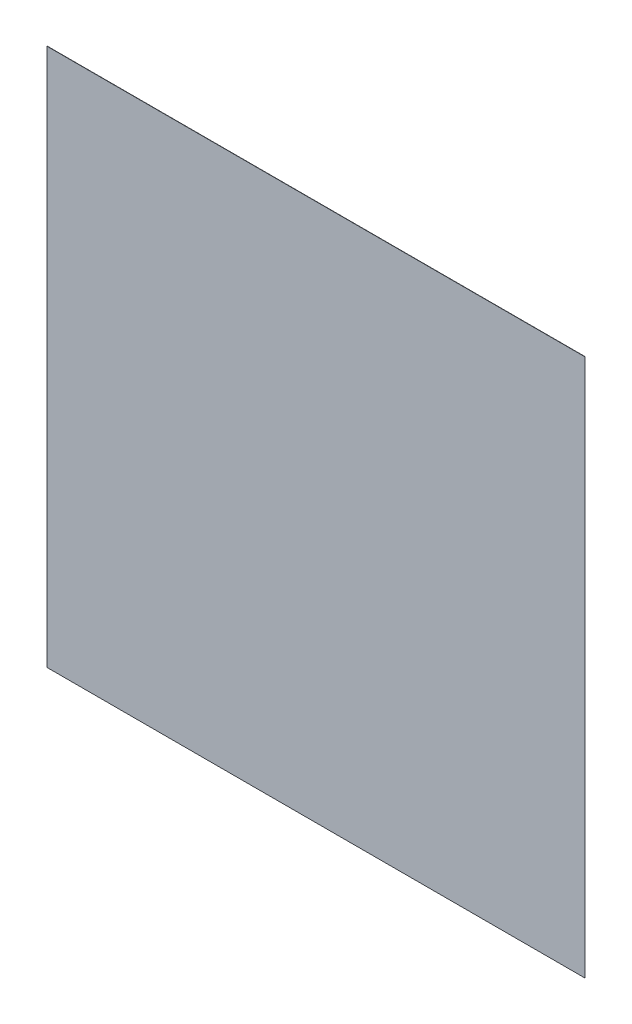
from build123d import *

# Parameters (mm, degrees)
ESQUISSE1_W        = 2000
ESQUISSE1_H        = 2000
BOSS_EXTRU_1_DEPTH = 1


with BuildPart() as part:
    # Esquisse1 → Boss.-Extru.1 (new body)
    with BuildSketch(Plane.XY):
        with Locations((1000, 362.878968322)):
            Rectangle(ESQUISSE1_W, ESQUISSE1_H)
    extrude(amount=BOSS_EXTRU_1_DEPTH)


solid = part.part
